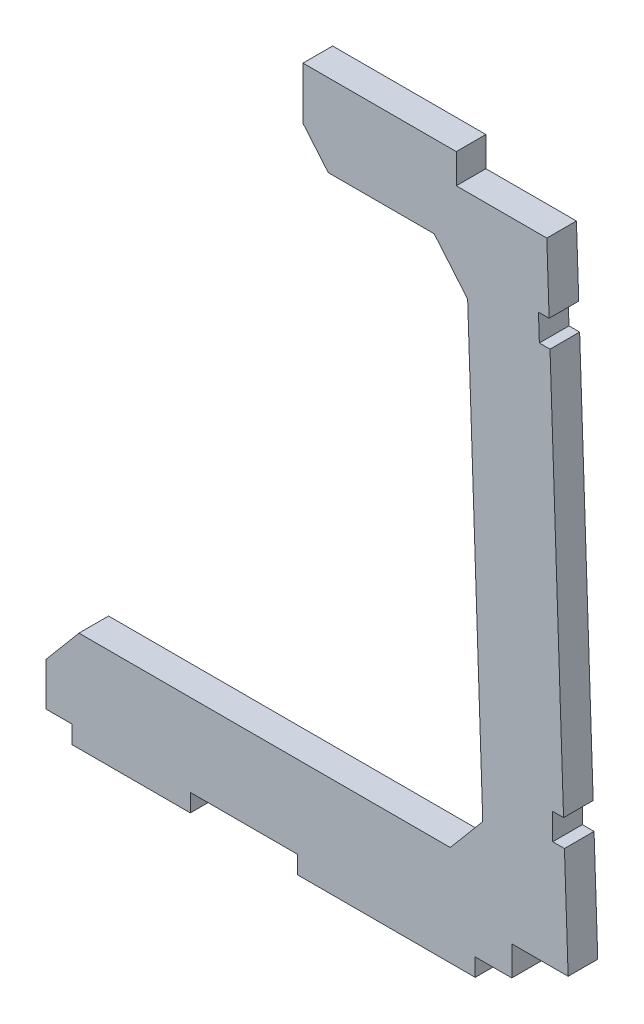
from build123d import *

# Parameters (mm, degrees)
BOSS_EXTRUDE1_DEPTH = 5


with BuildPart() as part:
    # Sketch1 → Boss-Extrude1 (new body)
    with BuildSketch(Plane.XY):
        Polygon((19.069352218, 7.305175864), (19.069352218, 0), (23.390509928, 0), (23.390509928, -3), (43.390509928, -3), (43.390509928, 0), (61.479859656, 0), (61.479859656, -3), (91.479859656, -3), (91.479859656, 0), (97.658870124, 0), (97.658870124, 5), (107.170761617, 5), (106.547030036, 23.375928632), (104.56994049, 23.375928632), (104.56994049, 27.816923755), (106.396289958, 27.816923755), (104.110516804, 95.158718868), (102.311123929, 95.158718868), (102.160383851, 99.599713991), (103.959776726, 99.599713991), (103.568446166, 111.128811841), (88.285450009, 111.128811841), (88.285450009, 116.128811841), (62.413977349, 116.128811841), (62.413977349, 107.324012391), (66.675181317, 102.245707253), (84.561926801, 102.245707253), (90.207225314, 95.517902469), (92.756368757, 20.416882452), (87.27387816, 13.883104587), (24.588889784, 13.883104587), align=None)
    extrude(amount=BOSS_EXTRUDE1_DEPTH)


solid = part.part
